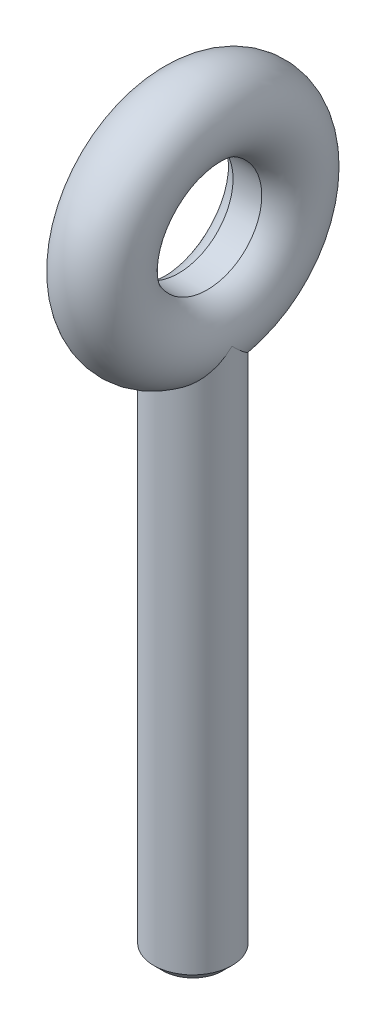
from build123d import *

# Parameters (mm, degrees)
VARREDURA_DA_ARGOLA_PROFILE_R = 2.15
VARREDURA_DO_PINO_PROFILE_R   = 2.15
CHANFRO_DO_PINO_SIZE          = 0.5
CORTE_EXTRUS_O1_DEPTH         = 36.787497843
CORTE_EXTRUS_O1_DEPTH_BACK    = 36.787497843
ESBO_O1_R                     = 3
ESBO_O1_R_2                   = 2.85


with BuildPart() as part:
    # Varredura da Argola: sweep along a path in Argola
    with BuildLine(Plane(origin=(0, 0, 0), x_dir=(0, 0, -1), z_dir=(1, 0, 0))) as varredura_da_argola_path:
        CenterArc((0, 0), 5, 0, 360)
    # Varredura da Argola profile (on start of the path) → Varredura da Argola (sweep)
    with BuildSketch(Plane(origin=(0, 0, -5), x_dir=(0, 0, 1), z_dir=(0, 1, 0))):
        Circle(VARREDURA_DA_ARGOLA_PROFILE_R)
    sweep(path=varredura_da_argola_path.line)

    # Varredura do Pino: sweep along a path in Pino
    with BuildLine(Plane(origin=(0, 0, 0), x_dir=(0, 0, -1), z_dir=(1, 0, 0))) as varredura_do_pino_path:
        Line((0, -5), (0, -35))
    # Varredura do Pino profile (on start of the path) → Varredura do Pino (sweep)
    with BuildSketch(Plane(origin=(0, -5, 0), x_dir=(0, 0, -1), z_dir=(0, -1, 0))):
        Circle(VARREDURA_DO_PINO_PROFILE_R)
    sweep(path=varredura_do_pino_path.line)

    # Chanfro do pino
    chanfro_do_pino_edges = [part.edges().sort_by_distance(p)[0] for p in [
        (0, -35, 2.15),
    ]]
    chamfer(chanfro_do_pino_edges, length=CHANFRO_DO_PINO_SIZE)

    # Esboço1 → Corte-extrusão1 (cut, two sides: drawn at the far end of the back side and taken through both)
    with BuildSketch(Plane(origin=(0, 0, 0), x_dir=(0, 0, -1), z_dir=(1, 0, 0)).offset(-CORTE_EXTRUS_O1_DEPTH_BACK)):
        Circle(ESBO_O1_R)
        Circle(ESBO_O1_R_2, mode=Mode.SUBTRACT)
    extrude(amount=CORTE_EXTRUS_O1_DEPTH + CORTE_EXTRUS_O1_DEPTH_BACK, mode=Mode.SUBTRACT)


solid = part.part
